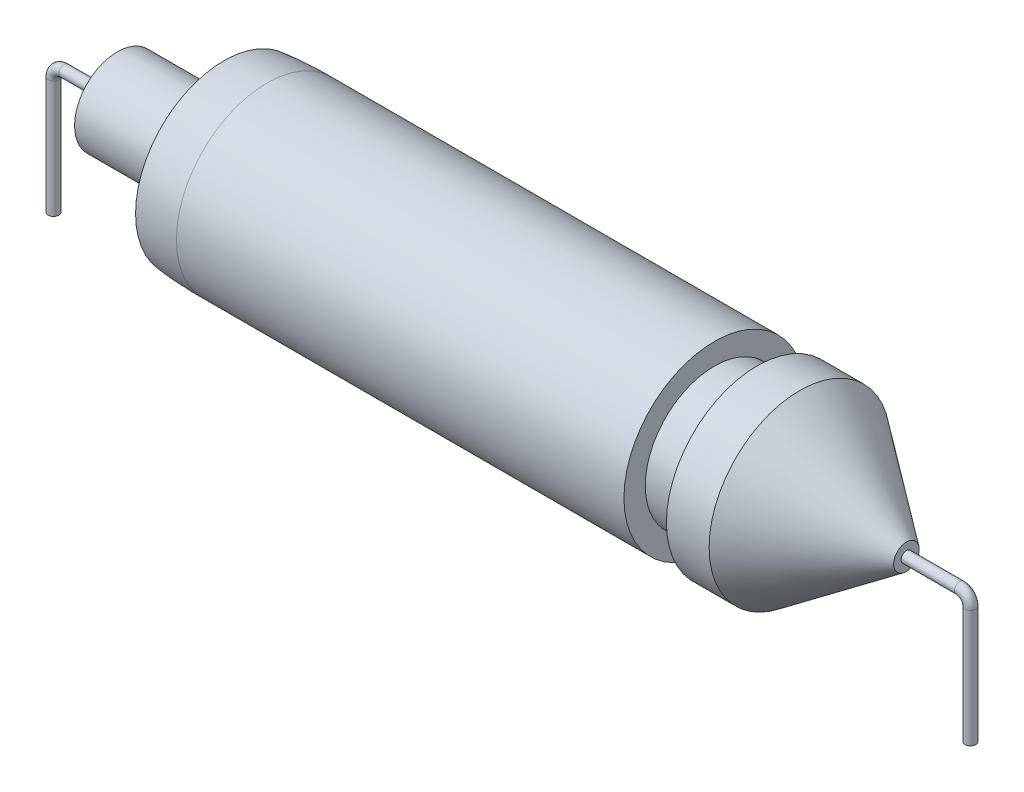
from build123d import *

# Parameters (mm, degrees)
SWEEP7_PROFILE_R = 250
SWEEP8_PROFILE_R = 250


with BuildPart() as part:
    # Sweep7: sweep along a path in Sketch3
    with BuildLine(Plane.XY) as sweep7_path:
        Line((18854.001725824, 0), (21354.001725824, 0))
        ThreePointArc((21354.001725824, 0), (21707.555116417, -146.446609407), (21854.001725824, -500))
        Line((21854.001725824, -500), (21854.001725824, -6000))
    # Sweep7 profile (on start of the path) → Sweep7 (sweep)
    with BuildSketch(Plane(origin=(18854.001725824, 0, 0), x_dir=(0, 0, 1), z_dir=(1, 0, 0))):
        Circle(SWEEP7_PROFILE_R)
    sweep(path=sweep7_path.line)



with BuildPart() as body_2:
    # Sweep8: sweep along a path in Sketch6
    with BuildLine(Plane.XY) as sweep8_path:
        Line((-18134.91260846, 0), (-20621.58680634, 0))
        ThreePointArc((-20621.58680634, 0), (-20975.140196933, -146.446609407), (-21121.58680634, -500))
        Line((-21121.58680634, -500), (-21121.58680634, -6000))
    # Sweep8 profile (on start of the path) → Sweep8 (sweep)
    with BuildSketch(Plane(origin=(-18134.91260846, 0, 0), x_dir=(0, 0, -1), z_dir=(-1, 0, 0))):
        Circle(SWEEP8_PROFILE_R)
    sweep(path=sweep8_path.line)


with BuildPart() as part_1:
    add(part.part)

    add(body_2.part)  # Revolve2 merges body 2
    # Sketch1 one side → Revolve2 (revolve)
    with BuildSketch(Plane(origin=(0, 0, 0), x_dir=(1, 0, 0), z_dir=(0, 1, 0))):
        with BuildLine():
            add(Edge.make_bspline(
                [(-11120.568434243, -4241.453892715), (-12129.425967311, -4249.987121585), (-13134.91260846, -4141.951449371)],
                knots=[0, 0, 0, 1, 1, 1], degree=2))
            Line((-11120.568434243, -4241.453892715), (9854.001725824, -4241.453892715))
            Line((9854.001725824, -4241.453892715), (9854.001725824, -3241.453892715))
            Line((9854.001725824, -3241.453892715), (11854.001725824, -3241.453892715))
            Line((11854.001725824, -3241.453892715), (11854.001725824, -4250))
            Line((11854.001725824, -4250), (13854.001725824, -4250))
            Line((13854.001725824, -4250), (18854.001725824, -600))
            Line((18854.001725824, -600), (18854.001725824, 0))
            Line((18854.001725824, 0), (-18134.91260846, 0))
            Line((-18134.91260846, 0), (-18134.91260846, -2000))
            Line((-18134.91260846, -2000), (-13134.91260846, -2000))
            Line((-13134.91260846, -2000), (-13134.91260846, -4141.951449371))
        make_face()
    revolve(axis=Axis((-24280.039694843, 0, 0), (1, 0, 0)))


solid = part_1.part
